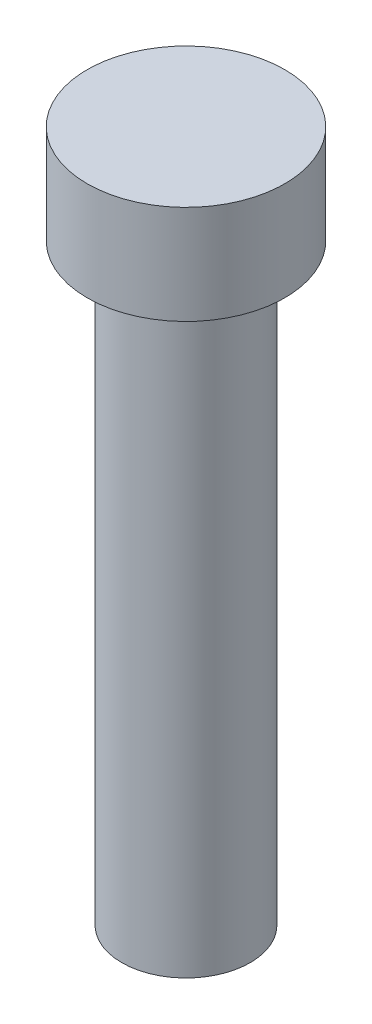
from build123d import *

# Parameters (mm, degrees)
SKETCH1_R           = 3.25
BOSS_EXTRUDE1_DEPTH = 30
SKETCH2_R           = 5
BOSS_EXTRUDE2_DEPTH = 5


with BuildPart() as part:
    # Sketch1 → Boss-Extrude1 (new body)
    with BuildSketch(Plane(origin=(0, 0, 0), x_dir=(1, 0, 0), z_dir=(0, 1, 0))):
        Circle(SKETCH1_R)
    extrude(amount=BOSS_EXTRUDE1_DEPTH)

    # Sketch2 → Boss-Extrude2 (add)
    with BuildSketch(Plane(origin=(0, 30, 0), x_dir=(1, 0, 0), z_dir=(0, 1, 0))):
        Circle(SKETCH2_R)
    extrude(amount=BOSS_EXTRUDE2_DEPTH)


solid = part.part
